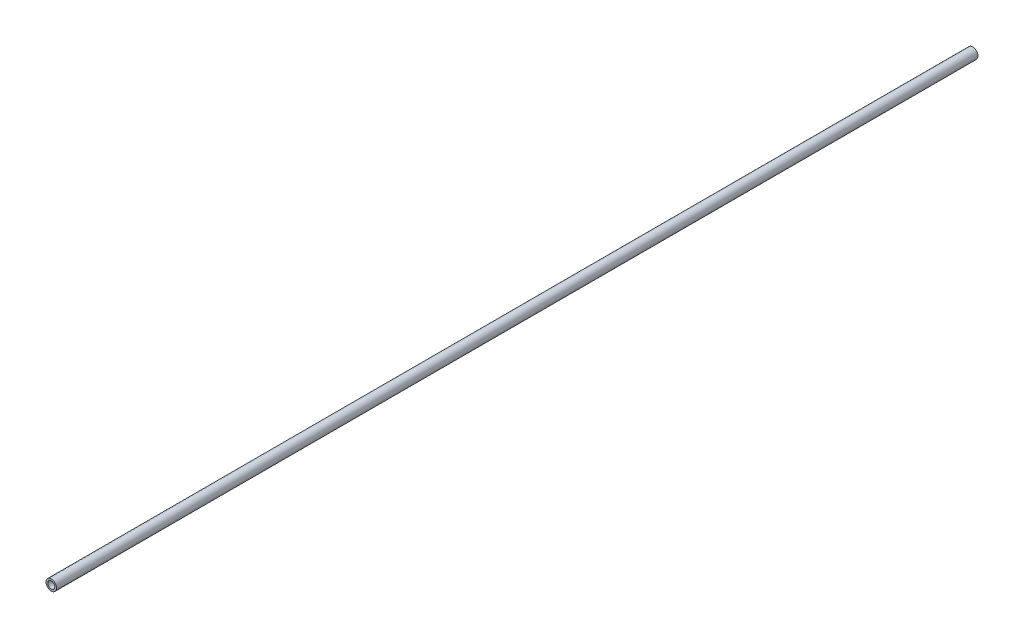
from build123d import *

# Parameters (mm, degrees)
SKETCH1_R           = 7.62
SKETCH1_R_2         = 5.08
BOSS_EXTRUDE1_DEPTH = 1333.5


with BuildPart() as part:
    # Sketch1 → Boss-Extrude1 (new body)
    with BuildSketch(Plane.XY):
        Circle(SKETCH1_R)
        Circle(SKETCH1_R_2, mode=Mode.SUBTRACT)
    extrude(amount=BOSS_EXTRUDE1_DEPTH)


solid = part.part
